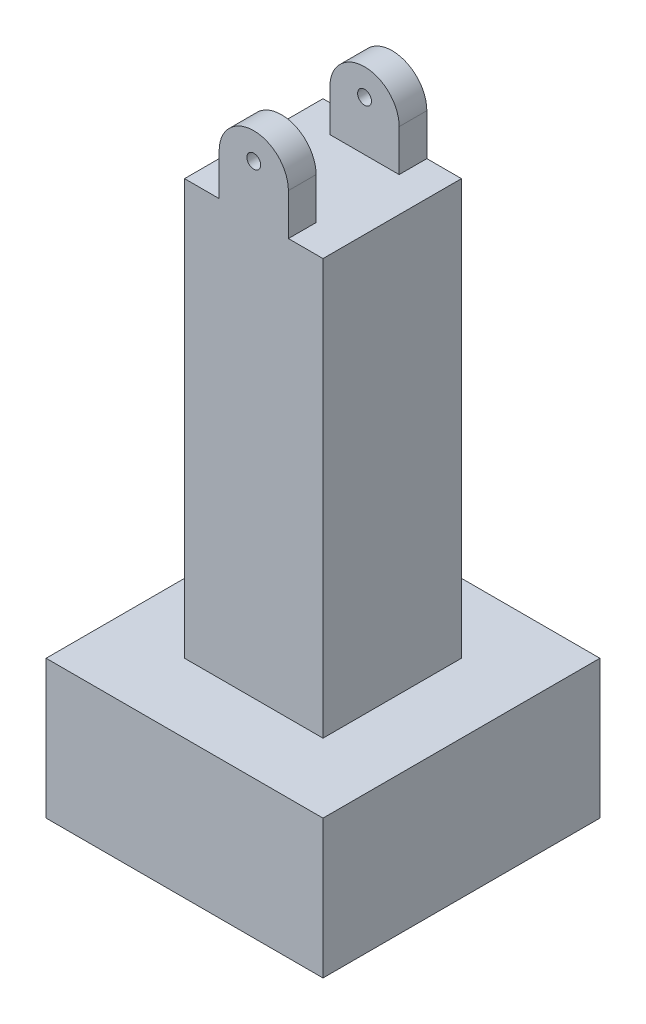
from build123d import *

# Parameters (mm, degrees)
SKETCH1_W           = 20
SKETCH1_H           = 20
BOSS_EXTRUDE1_DEPTH = 10
SKETCH2_W           = 10
SKETCH2_H           = 10
BOSS_EXTRUDE2_DEPTH = 30
SKETCH3_W           = 5
SKETCH3_H           = 2
BOSS_EXTRUDE3_DEPTH = 3
SKETCH4_R           = 2.5
BOSS_EXTRUDE4_DEPTH = 2
SKETCH5_R           = 0.5
CUT_EXTRUDE1_DEPTH  = 10


with BuildPart() as part:
    # Sketch1 → Boss-Extrude1 (new body)
    with BuildSketch(Plane(origin=(0, 0, 0), x_dir=(1, 0, 0), z_dir=(0, 1, 0))):
        Rectangle(SKETCH1_W, SKETCH1_H)
    extrude(amount=BOSS_EXTRUDE1_DEPTH)

    # Sketch2 → Boss-Extrude2 (add)
    with BuildSketch(Plane(origin=(0, 10, 0), x_dir=(-1, 0, 0), z_dir=(0, -1, 0))):
        Rectangle(SKETCH2_W, SKETCH2_H)
    extrude(amount=-BOSS_EXTRUDE2_DEPTH)

    # Sketch3 → Boss-Extrude3 (add)
    with BuildSketch(Plane(origin=(0, 40, 0), x_dir=(1, 0, 0), z_dir=(0, 1, 0))):
        with Locations((0, 4)):
            Rectangle(SKETCH3_W, SKETCH3_H)
        with Locations((0, -4)):
            Rectangle(SKETCH3_W, SKETCH3_H)
    extrude(amount=BOSS_EXTRUDE3_DEPTH)

    # Sketch4 → Boss-Extrude4 (add)
    with BuildSketch(Plane(origin=(0, 0, -5), x_dir=(1, 0, 0), z_dir=(0, 0, -1))):
        with Locations((0, -43)):
            Circle(SKETCH4_R)
    boss_extrude4 = extrude(amount=-BOSS_EXTRUDE4_DEPTH)

    # Mirror1: Boss-Extrude4 across plane
    add(boss_extrude4.mirror(Plane.XY))

    # Sketch5 → Cut-Extrude1 (cut)
    with BuildSketch(Plane(origin=(0, 0, -5), x_dir=(-1, 0, 0), z_dir=(0, 0, -1))):
        with Locations((0, 43.589170062)):
            Circle(SKETCH5_R)
    extrude(amount=-CUT_EXTRUDE1_DEPTH, mode=Mode.SUBTRACT)


solid = part.part
